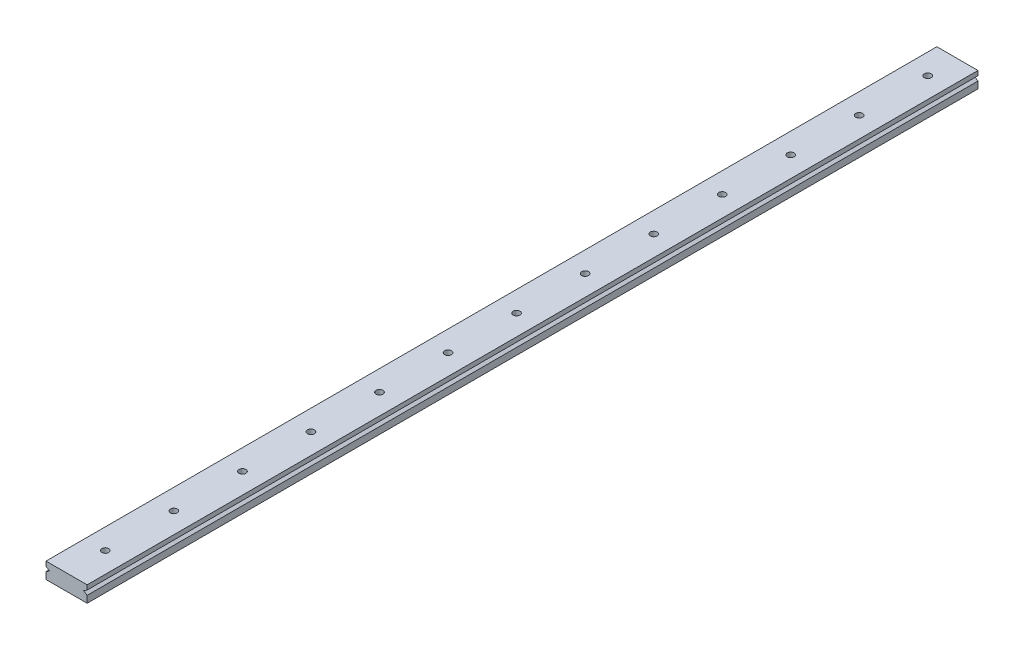
from build123d import *

# Parameters (mm, degrees)
SKETCH1_W           = 18
SKETCH1_H           = 7
BOSS_EXTRUDE1_DEPTH = 390
SKETCH3_R           = 1.5
CUT_EXTRUDE1_DEPTH  = 390
CUT_EXTRUDE2_DEPTH  = 390


with BuildPart() as part:
    # Sketch1 → Boss-Extrude1 (new body)
    with BuildSketch(Plane.XY):
        Rectangle(SKETCH1_W, SKETCH1_H)
    extrude(amount=BOSS_EXTRUDE1_DEPTH)

    # Sketch3 → Cut-Extrude1 (cut)
    with BuildSketch(Plane(origin=(0, 3.5, 0), x_dir=(1, 0, 0), z_dir=(0, 1, 0))):
        with Locations((0, -13)):
            Circle(SKETCH3_R)
        with Locations((0, -43)):
            Circle(SKETCH3_R)
        with Locations((0, -73)):
            Circle(SKETCH3_R)
        with Locations((0, -103)):
            Circle(SKETCH3_R)
        with Locations((0, -133)):
            Circle(SKETCH3_R)
        with Locations((0, -163)):
            Circle(SKETCH3_R)
        with Locations((0, -193)):
            Circle(SKETCH3_R)
        with Locations((0, -223)):
            Circle(SKETCH3_R)
        with Locations((0, -253)):
            Circle(SKETCH3_R)
        with Locations((0, -283)):
            Circle(SKETCH3_R)
        with Locations((0, -313)):
            Circle(SKETCH3_R)
        with Locations((0, -343)):
            Circle(SKETCH3_R)
        with Locations((0, -373)):
            Circle(SKETCH3_R)
    extrude(amount=-CUT_EXTRUDE1_DEPTH, mode=Mode.SUBTRACT)

    # Sketch5 → Cut-Extrude2 (cut)
    with BuildSketch(Plane(origin=(0, 0, 0), x_dir=(-1, 0, 0), z_dir=(0, 0, -1))):
        Polygon((-9, 1.5), (-9, -0.5), (-7.5, 0.5), align=None)
        Polygon((9, -0.5), (9, 1.5), (7.5, 0.5), align=None)
    extrude(amount=-CUT_EXTRUDE2_DEPTH, mode=Mode.SUBTRACT)


solid = part.part
